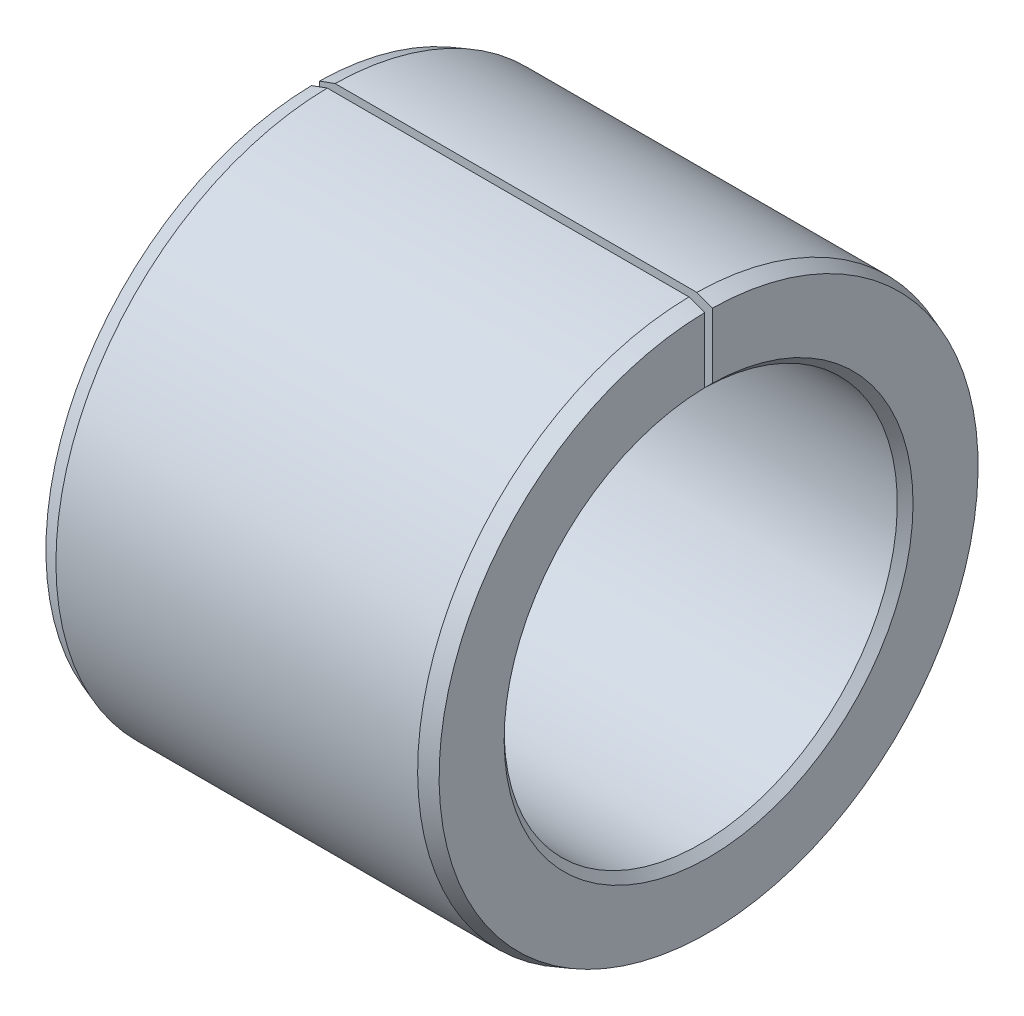
from build123d import *

# Parameters (mm, degrees)
SKETCH_2_W          = 0.1
SKETCH_2_H          = 3.5
CUT_EXTRUDE_1_DEPTH = 6


with BuildPart() as part:
    # 草图1 → 旋转1 (revolve)
    with BuildSketch(Plane.XY):
        Polygon((0.2, 3.5), (4.8, 3.5), (5, 3.427205953), (5, 2.6), (4.9, 2.5), (0.1, 2.5), (0, 2.6), (0, 3.427205953), align=None)
    revolve(axis=Axis((0, 0, 0), (1, 0, 0)))

    # 草图2 → 切除-拉伸1 (cut, through all)
    with BuildSketch(Plane(origin=(0, 0, 0), x_dir=(0, 0, -1), z_dir=(1, 0, 0))):
        with Locations((0, 1.75)):
            Rectangle(SKETCH_2_W, SKETCH_2_H)
    extrude(amount=CUT_EXTRUDE_1_DEPTH, mode=Mode.SUBTRACT)


solid = part.part
